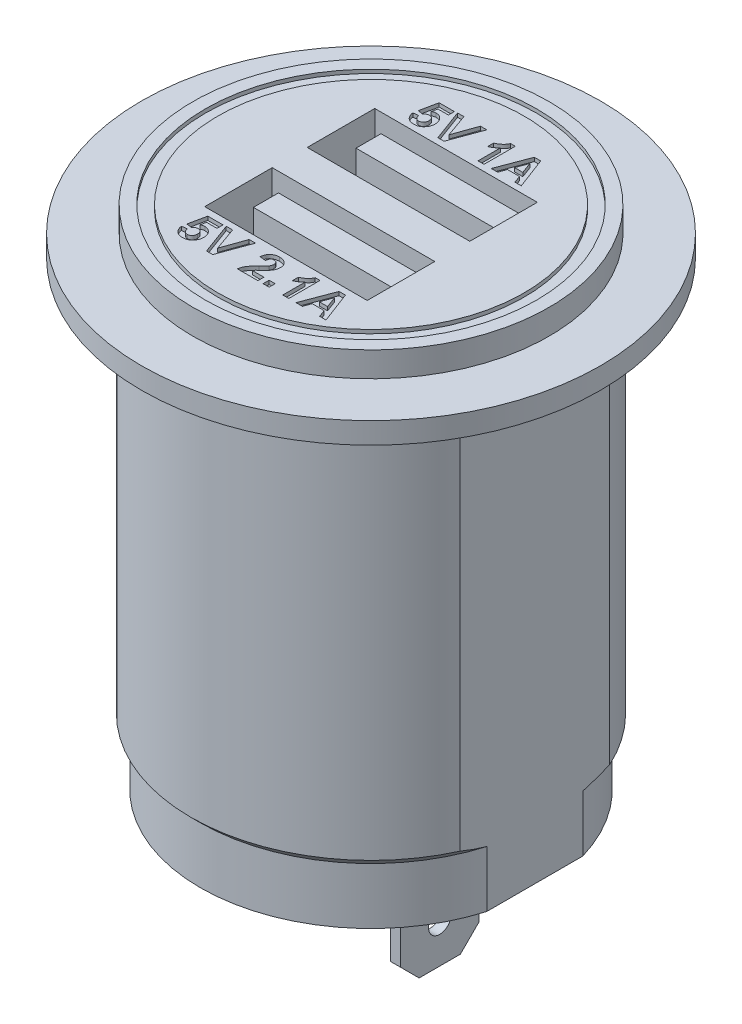
from build123d import *

# Parameters (mm, degrees)
SKETCH_2_W          = 2.6
SKETCH_2_H          = 11.958260744
CUT_EXTRUDE_1_DEPTH = 36.8
SKETCH_3_W          = 0.8
SKETCH_3_H          = 6.3
EXTRUDE_1_DEPTH     = 9.5
CHAMFER_1_SIZE      = 1.5
SKETCH_4_R          = 0.9
CUT_EXTRUDE_2_DEPTH = 24.85
SKETCH_5_W          = 13
SKETCH_5_H          = 5.4
CUT_EXTRUDE_3_DEPTH = 10
SKETCH_6_W          = 11
SKETCH_6_H          = 2
EXTRUDE_2_DEPTH     = 9
SKETCH_7_W          = 0.480769231
SKETCH_7_H          = 0.480769231
CUT_EXTRUDE_4_DEPTH = 0.3
SKETCH_8_R          = 13.25
SKETCH_8_R_2        = 12.25
CUT_EXTRUDE_5_DEPTH = 0.3


with BuildPart() as part:
    # Эскиз1 → Повернуть1 (revolve)
    with BuildSketch(Plane.XY):
        Polygon((0, 0), (-13.65, 0), (-13.65, 4.5), (-14.4, 5.25), (-14.4, 36.8), (-18.35, 36.8), (-18.35, 38.5), (-14.25, 38.5), (-14.25, 40.5), (0, 40.5), align=None)
    revolve(axis=Axis((0, 0, 0), (0, 1, 0)))

    # Эскиз2 → Вырез-Вытянуть1 (cut)
    with BuildSketch(Plane.XZ):
        with Locations((14.4, 0)):
            Rectangle(SKETCH_2_W, SKETCH_2_H)
        with Locations((-14.4, 0)):
            Rectangle(SKETCH_2_W, SKETCH_2_H)
    extrude(amount=-CUT_EXTRUDE_1_DEPTH, mode=Mode.SUBTRACT)

    # Эскиз3 → Бобышка-Вытянуть1 (add)
    with BuildSketch(Plane.XZ):
        with Locations((5.1, 0)):
            Rectangle(SKETCH_3_W, SKETCH_3_H)
        with Locations((-5.1, 0)):
            Rectangle(SKETCH_3_W, SKETCH_3_H)
    extrude(amount=EXTRUDE_1_DEPTH)

    # Фаска1
    chamfer_1_edges = [part.edges().sort_by_distance(p)[0] for p in [
        (5.1, -9.5, -3.15),
        (5.1, -9.5, 3.15),
        (-5.1, -9.5, -3.15),
        (-5.1, -9.5, 3.15),
    ]]
    chamfer(chamfer_1_edges, length=CHAMFER_1_SIZE)

    # Эскиз4 → Вырез-Вытянуть2 (cut, through all)
    with BuildSketch(Plane.ZY.offset(5.5)):
        with Locations((0, -6.4)):
            Circle(SKETCH_4_R)
    extrude(amount=-CUT_EXTRUDE_2_DEPTH, mode=Mode.SUBTRACT)

    # Эскиз5 → Вырез-Вытянуть3 (cut)
    with BuildSketch(Plane(origin=(0, 40.5, 0), x_dir=(1, 0, 0), z_dir=(0, 1, 0))):
        with Locations((0, 4.1)):
            Rectangle(SKETCH_5_W, SKETCH_5_H)
        with Locations((0, -4.1)):
            Rectangle(SKETCH_5_W, SKETCH_5_H)
    extrude(amount=-CUT_EXTRUDE_3_DEPTH, mode=Mode.SUBTRACT)

    # Эскиз6 → Бобышка-Вытянуть2 (add)
    with BuildSketch(Plane(origin=(0, 30.5, 0), x_dir=(1, 0, 0), z_dir=(0, 1, 0))):
        with Locations((0, 5.3)):
            Rectangle(SKETCH_6_W, SKETCH_6_H)
        with Locations((0, -2.9)):
            Rectangle(SKETCH_6_W, SKETCH_6_H)
    extrude(amount=EXTRUDE_2_DEPTH)

    # Эскиз7 → Вырез-Вытянуть4 (cut)
    with BuildSketch(Plane(origin=(0, 40.5, 0), x_dir=(1, 0, 0), z_dir=(0, 1, 0))):
        with BuildLine():
            Line((-6.071794872, -9.084855769), (-5.655128205, -9.030769231))
            add(Edge.make_bspline(
                [(-5.655128205, -9.030769231), (-5.65051875, -9.059026222), (-5.641642486, -9.113439714), (-5.614087877, -9.18940513), (-5.575714302, -9.256327628), (-5.526397261, -9.312679014), (-5.470268278, -9.358509144), (-5.408259878, -9.391182056), (-5.342250284, -9.411752917), (-5.296533961, -9.414168478), (-5.273517628, -9.415384615)],
                knots=[0, 0, 0, 0, 8.5742e-05, 0.000165111, 0.000240957, 0.000315865, 0.000388525, 0.000457076, 0.000525047, 0.000593964, 0.000593964, 0.000593964, 0.000593964], degree=3))
            add(Edge.make_bspline(
                [(-5.273517628, -9.415384615), (-5.260146267, -9.415149695), (-5.233971622, -9.414689835), (-5.195399511, -9.409469834), (-5.158552543, -9.400989158), (-5.123082097, -9.389479305), (-5.08935762, -9.374341406), (-5.057349128, -9.355816579), (-5.026937002, -9.333878798), (-4.997967309, -9.309072892), (-4.97119908, -9.280751154), (-4.948827523, -9.248150737), (-4.92900915, -9.212937652), (-4.912864338, -9.174155273), (-4.901226177, -9.131667688), (-4.891967182, -9.086202257), (-4.887247394, -9.037210068), (-4.886357083, -9.00356705), (-4.885897436, -8.986197917)],
                knots=[0, 0, 0, 0, 4.0092e-05, 7.8481e-05, 0.000116506, 0.000153406, 0.000190169, 0.000227192, 0.000264159, 0.000302509, 0.000341488, 0.000380669, 0.000420799, 0.000462558, 0.000506309, 0.000552765, 0.0006016, 0.000653722, 0.000653722, 0.000653722, 0.000653722], degree=3))
            add(Edge.make_bspline(
                [(-4.885897436, -8.986197917), (-4.886157335, -8.969825462), (-4.886659633, -8.938182995), (-4.891319785, -8.892338403), (-4.898473093, -8.849496208), (-4.909852877, -8.809969649), (-4.922849485, -8.773023923), (-4.94037219, -8.739968513), (-4.959599064, -8.709367422), (-4.983033703, -8.682871734), (-5.008567883, -8.659461096), (-5.035761697, -8.638602602), (-5.064920412, -8.621198196), (-5.095753688, -8.606260119), (-5.128796018, -8.595379296), (-5.163779387, -8.588140334), (-5.200233405, -8.582706053), (-5.22525255, -8.582271837), (-5.237960737, -8.582051282)],
                knots=[0, 0, 0, 0, 4.9102e-05, 9.4897e-05, 0.000138123, 0.000179191, 0.00021817, 0.000255351, 0.000291189, 0.000326335, 0.000361067, 0.000395022, 0.000428947, 0.000462773, 0.000497614, 0.000532976, 0.000569876, 0.000607967, 0.000607967, 0.000607967, 0.000607967], degree=3))
            add(Edge.make_bspline(
                [(-5.237960737, -8.582051282), (-5.254027815, -8.58262731), (-5.286081887, -8.583776496), (-5.333399457, -8.593118254), (-5.379455586, -8.6083267), (-5.424202404, -8.629497916), (-5.467521526, -8.656801079), (-5.509225401, -8.690326736), (-5.550029899, -8.729498078), (-5.575094389, -8.75909502), (-5.588020833, -8.774358974)],
                knots=[0, 0, 0, 0, 4.8171e-05, 9.6101e-05, 0.000144087, 0.000193372, 0.000244227, 0.000297334, 0.000353649, 0.000413622, 0.000413622, 0.000413622, 0.000413622], degree=3))
            Line((-5.588020833, -8.774358974), (-6.007692308, -8.715264423))
            Line((-6.007692308, -8.715264423), (-5.719230769, -7.332051282))
            Line((-5.719230769, -7.332051282), (-4.501282051, -7.332051282))
            Line((-4.501282051, -7.332051282), (-4.501282051, -7.812820513))
            Line((-4.501282051, -7.812820513), (-5.333613782, -7.812820513))
            Line((-5.333613782, -7.812820513), (-5.431770833, -8.259034455))
            add(Edge.make_bspline(
                [(-5.431770833, -8.259034455), (-5.406757602, -8.244602606), (-5.358046667, -8.216497927), (-5.280279335, -8.187566738), (-5.202112513, -8.168998235), (-5.149419679, -8.166582922), (-5.123277244, -8.165384615)],
                knots=[0, 0, 0, 0, 8.6492e-05, 0.000168436, 0.000248014, 0.00032637, 0.00032637, 0.00032637, 0.00032637], degree=3))
            add(Edge.make_bspline(
                [(-5.123277244, -8.165384615), (-5.098701132, -8.166045968), (-5.050153791, -8.167352395), (-4.978955064, -8.178071214), (-4.910661949, -8.195736928), (-4.845043836, -8.220320618), (-4.782570071, -8.252543421), (-4.722702089, -8.291489581), (-4.666304201, -8.33783492), (-4.612770435, -8.390241405), (-4.563951397, -8.448222876), (-4.521792274, -8.511448733), (-4.485378999, -8.578344249), (-4.455734276, -8.649648534), (-4.43341095, -8.725460788), (-4.416692937, -8.805128206), (-4.407327625, -8.889153856), (-4.405871334, -8.946445703), (-4.405128205, -8.97568109)],
                knots=[0, 0, 0, 0, 7.3701e-05, 0.000145588, 0.000215432, 0.000285007, 0.000355335, 0.000425899, 0.000498873, 0.00057395, 0.000650382, 0.000725804, 0.000801544, 0.000878552, 0.00095698, 0.001038304, 0.001122478, 0.001210188, 0.001210188, 0.001210188, 0.001210188], degree=3))
            add(Edge.make_bspline(
                [(-4.405128205, -8.97568109), (-4.405798933, -9.000236398), (-4.407130192, -9.048973779), (-4.414917043, -9.121095104), (-4.429453598, -9.191092415), (-4.447971061, -9.259360034), (-4.473562437, -9.325325991), (-4.503931524, -9.389420337), (-4.540234787, -9.451527978), (-4.568243305, -9.490713991), (-4.582411859, -9.510536859)],
                knots=[0, 0, 0, 0, 7.3679e-05, 0.000146238, 0.000217248, 0.000287966, 0.000358187, 0.000429196, 0.000500573, 0.000573643, 0.000573643, 0.000573643, 0.000573643], degree=3))
            add(Edge.make_bspline(
                [(-4.582411859, -9.510536859), (-4.603066772, -9.536061879), (-4.643718042, -9.586298089), (-4.713307615, -9.652346218), (-4.7889948, -9.707815105), (-4.870574601, -9.75336909), (-4.957960108, -9.789116493), (-5.051545596, -9.813969732), (-5.150644882, -9.829346086), (-5.218706018, -9.831136415), (-5.253485577, -9.832051282)],
                knots=[0, 0, 0, 0, 9.8429e-05, 0.000193719, 0.000286874, 0.000379245, 0.00047336, 0.000569333, 0.000669128, 0.000773415, 0.000773415, 0.000773415, 0.000773415], degree=3))
            add(Edge.make_bspline(
                [(-5.253485577, -9.832051282), (-5.281558918, -9.831544204), (-5.336373649, -9.830554105), (-5.416648595, -9.820762771), (-5.492722758, -9.804855481), (-5.565076081, -9.782780924), (-5.633278959, -9.754111375), (-5.697861313, -9.719498174), (-5.758285061, -9.678174124), (-5.814271958, -9.630451413), (-5.865683396, -9.577703979), (-5.911540136, -9.519988728), (-5.952340623, -9.458270932), (-5.987306455, -9.391926961), (-6.017105607, -9.321422091), (-6.040832947, -9.246394983), (-6.060368841, -9.167345985), (-6.067944037, -9.112656866), (-6.071794872, -9.084855769)],
                knots=[0, 0, 0, 0, 8.4188e-05, 0.000164382, 0.000242173, 0.000317101, 0.00039095, 0.000463773, 0.00053656, 0.000610109, 0.000684128, 0.000757178, 0.000830934, 0.00090576, 0.000981843, 0.001060239, 0.001141622, 0.001225769, 0.001225769, 0.001225769, 0.001225769], degree=3))
        make_face()
        Polygon((-3.35244391, -9.8), (-4.276923077, -7.3), (-3.769110577, -7.3), (-3.107051282, -9.158974359), (-2.447495994, -7.3), (-1.937179487, -7.3), (-2.858153045, -9.8), align=None)
        with BuildLine():
            Line((0.755128205, -9.319230769), (0.755128205, -9.8))
            Line((0.755128205, -9.8), (-0.879487179, -9.8))
            add(Edge.make_bspline(
                [(-0.879487179, -9.8), (-0.873952751, -9.758911294), (-0.862886996, -9.67675692), (-0.828675638, -9.556750059), (-0.783015195, -9.439643865), (-0.733459457, -9.344347849), (-0.684170786, -9.267637836), (-0.639451172, -9.204781058), (-0.586102314, -9.137904144), (-0.524898363, -9.066467212), (-0.456177556, -8.990246952), (-0.379427192, -8.909526734), (-0.294281159, -8.824692989), (-0.234379408, -8.767086702), (-0.203405449, -8.737299679)],
                knots=[0, 0, 0, 0, 0.000124241, 0.000248413, 0.000373217, 0.000500896, 0.000569803, 0.00064665, 0.000732215, 0.000826351, 0.00092883, 0.001040059, 0.00116046, 0.001289377, 0.001289377, 0.001289377, 0.001289377], degree=3))
            add(Edge.make_bspline(
                [(-0.203405449, -8.737299679), (-0.178687875, -8.713440453), (-0.131632893, -8.668019514), (-0.064626509, -8.60297857), (-0.005720992, -8.543187455), (0.046315289, -8.490195613), (0.090280224, -8.442653738), (0.12675213, -8.401308468), (0.15619292, -8.365991431), (0.172138077, -8.343586281), (0.179206731, -8.333653846)],
                knots=[0, 0, 0, 0, 0.000103064, 0.000196204, 0.000280131, 0.000354858, 0.000419001, 0.000474358, 0.00052027, 0.000556832, 0.000556832, 0.000556832, 0.000556832], degree=3))
            add(Edge.make_bspline(
                [(0.179206731, -8.333653846), (0.193681608, -8.309609529), (0.221601969, -8.263230827), (0.252218961, -8.190299479), (0.270596421, -8.117383196), (0.273118305, -8.068660953), (0.274358974, -8.044691506)],
                knots=[0, 0, 0, 0, 8.4106e-05, 0.000162231, 0.000236446, 0.000308313, 0.000308313, 0.000308313, 0.000308313], degree=3))
            add(Edge.make_bspline(
                [(0.274358974, -8.044691506), (0.273458558, -8.019748074), (0.27175504, -7.972557046), (0.257470747, -7.905961778), (0.232139873, -7.848713712), (0.19726392, -7.800637123), (0.153163208, -7.762969299), (0.101608193, -7.735136433), (0.041844192, -7.719748486), (-0.000161473, -7.717724491), (-0.022115385, -7.716666667)],
                knots=[0, 0, 0, 0, 7.4787e-05, 0.000141492, 0.000202917, 0.000261313, 0.000318132, 0.000375488, 0.00043562, 0.000501456, 0.000501456, 0.000501456, 0.000501456], degree=3))
            add(Edge.make_bspline(
                [(-0.022115385, -7.716666667), (-0.043920977, -7.717654596), (-0.086044675, -7.719563061), (-0.145911589, -7.736235151), (-0.19828409, -7.765096294), (-0.235607519, -7.79798635), (-0.260821266, -7.829969541), (-0.278001033, -7.857840785), (-0.292808651, -7.889511066), (-0.305929437, -7.924623828), (-0.316293374, -7.963581325), (-0.324639845, -8.006086858), (-0.331365894, -8.052369166), (-0.333504896, -8.084566443), (-0.334615385, -8.101282051)],
                knots=[0, 0, 0, 0, 6.5337e-05, 0.000126217, 0.000184491, 0.000243381, 0.000274041, 0.000306423, 0.000341368, 0.000378764, 0.000418734, 0.000462145, 0.000508677, 0.000558917, 0.000558917, 0.000558917, 0.000558917], degree=3))
            Line((-0.334615385, -8.101282051), (-0.815384615, -8.054206731))
            add(Edge.make_bspline(
                [(-0.815384615, -8.054206731), (-0.811519305, -8.021748748), (-0.804025086, -7.958817905), (-0.785323138, -7.868427517), (-0.761637813, -7.785038303), (-0.731839952, -7.70880502), (-0.697161138, -7.639242897), (-0.655832462, -7.577395758), (-0.609297991, -7.522578511), (-0.55751751, -7.474820331), (-0.500820204, -7.433969287), (-0.441326555, -7.397503461), (-0.37787389, -7.367589892), (-0.311160825, -7.342936617), (-0.24121751, -7.323233917), (-0.167720447, -7.310206758), (-0.091123232, -7.301043405), (-0.038837654, -7.300353044), (-0.012099359, -7.3)],
                knots=[0, 0, 0, 0, 9.8024e-05, 0.000190053, 0.000276592, 0.00035778, 0.000435274, 0.000509306, 0.000580356, 0.000650529, 0.000720045, 0.000789699, 0.000859589, 0.000930103, 0.001002885, 0.001077241, 0.001153838, 0.001234005, 0.001234005, 0.001234005, 0.001234005], degree=3))
            add(Edge.make_bspline(
                [(-0.012099359, -7.3), (0.016968622, -7.300558671), (0.073582164, -7.301646754), (0.156227886, -7.310632151), (0.233867603, -7.326299493), (0.307180097, -7.347053105), (0.375412488, -7.374760693), (0.439133353, -7.408258016), (0.497339838, -7.448816364), (0.55089959, -7.494223917), (0.598777722, -7.544157504), (0.640714634, -7.597420115), (0.67584924, -7.653974645), (0.70533257, -7.713131754), (0.727223744, -7.775843368), (0.743174605, -7.841242356), (0.753750669, -7.909633819), (0.754663948, -7.956343636), (0.755128205, -7.980088141)],
                knots=[0, 0, 0, 0, 8.7191e-05, 0.000169816, 0.000248977, 0.000324578, 0.000398046, 0.000469513, 0.000540082, 0.000610426, 0.000679848, 0.000747271, 0.000813414, 0.000879262, 0.000945155, 0.001012202, 0.001081044, 0.001152221, 0.001152221, 0.001152221, 0.001152221], degree=3))
            add(Edge.make_bspline(
                [(0.755128205, -7.980088141), (0.754516553, -8.007339288), (0.753303128, -8.061401383), (0.741685485, -8.141321309), (0.723935988, -8.219398293), (0.69770363, -8.295823146), (0.664452079, -8.372429123), (0.621590033, -8.449388173), (0.571823955, -8.529021246), (0.532859078, -8.580507502), (0.512740385, -8.607091346)],
                knots=[0, 0, 0, 0, 8.1706e-05, 0.000162092, 0.000241782, 0.0003216, 0.000404129, 0.000491979, 0.000585622, 0.000685588, 0.000685588, 0.000685588, 0.000685588], degree=3))
            add(Edge.make_bspline(
                [(0.512740385, -8.607091346), (0.505136402, -8.616668585), (0.488850433, -8.637180811), (0.46114372, -8.668633137), (0.429034023, -8.702988993), (0.392974878, -8.740891439), (0.351775179, -8.780998248), (0.306917294, -8.824986654), (0.256427346, -8.870606505), (0.204131995, -8.918995794), (0.151609333, -8.966092408), (0.103333434, -9.01082375), (0.059482854, -9.050401381), (0.022099797, -9.087010167), (-0.011014599, -9.118151585), (-0.038666782, -9.14542253), (-0.061374189, -9.168162796), (-0.092663535, -9.2036091), (-0.132475676, -9.251550242), (-0.160485145, -9.297359359), (-0.173858173, -9.319230769)],
                knots=[0, 0, 0, 0, 3.6682e-05, 7.8564e-05, 0.000125695, 0.000177762, 0.000235484, 0.000298172, 0.000366222, 0.000439595, 0.000511922, 0.000577849, 0.000637039, 0.000689105, 0.000734799, 0.0007734, 0.000805627, 0.000831163, 0.000915241, 0.000992061, 0.000992061, 0.000992061, 0.000992061], degree=3))
            Line((-0.173858173, -9.319230769), (0.755128205, -9.319230769))
        make_face()
        with Locations((1.412179487, -9.559615385)):
            Rectangle(SKETCH_7_W, SKETCH_7_H)
        with BuildLine():
            Line((3.223076923, -9.8), (2.742307692, -9.8))
            Line((2.742307692, -9.8), (2.742307692, -8.020152244))
            add(Edge.make_bspline(
                [(2.742307692, -8.020152244), (2.720516648, -8.042274218), (2.677230179, -8.08621806), (2.608094868, -8.147513859), (2.536321875, -8.204535114), (2.46120094, -8.256740226), (2.383714086, -8.304873027), (2.30306944, -8.34855373), (2.219851545, -8.388386718), (2.162202905, -8.410647172), (2.133333333, -8.421794872)],
                knots=[0, 0, 0, 0, 9.3134e-05, 0.000185005, 0.000276984, 0.000367982, 0.000459289, 0.000550496, 0.000643016, 0.000735826, 0.000735826, 0.000735826, 0.000735826], degree=3))
            Line((2.133333333, -8.421794872), (2.133333333, -7.941025641))
            add(Edge.make_bspline(
                [(2.133333333, -7.941025641), (2.165351142, -7.929020337), (2.232361924, -7.903894169), (2.331247303, -7.850449537), (2.434461306, -7.78427969), (2.52116696, -7.719382394), (2.590007686, -7.661683511), (2.638122119, -7.615302663), (2.682702908, -7.567806269), (2.722074349, -7.517661319), (2.757269962, -7.465881633), (2.788454809, -7.412551804), (2.815904643, -7.357503364), (2.83027444, -7.319168851), (2.837459936, -7.3)],
                knots=[0, 0, 0, 0, 0.000102482, 0.000214487, 0.000336323, 0.000470137, 0.00053907, 0.000605659, 0.000670511, 0.000734333, 0.0007967, 0.000858199, 0.000919567, 0.000980945, 0.000980945, 0.000980945, 0.000980945], degree=3))
            Line((2.837459936, -7.3), (3.223076923, -7.3))
            Line((3.223076923, -7.3), (3.223076923, -9.8))
        make_face()
        Polygon((6.203846154, -9.8), (5.694030449, -9.8), (5.483193109, -9.223076923), (4.523657853, -9.223076923), (4.312820513, -9.8), (3.8, -9.8), (4.745012019, -7.3), (5.254326923, -7.3), align=None)
        Polygon((5.330448718, -8.806410256), (5.001923077, -7.908974359), (4.674399038, -8.806410256), align=None, mode=Mode.SUBTRACT)
        with BuildLine():
            Line((-4.671794872, 8.015144231), (-4.255128205, 8.069230769))
            add(Edge.make_bspline(
                [(-4.255128205, 8.069230769), (-4.25051875, 8.040973778), (-4.241642486, 7.986560286), (-4.214087877, 7.91059487), (-4.175714302, 7.843672372), (-4.126397261, 7.787320986), (-4.070268278, 7.741490856), (-4.008259878, 7.708817944), (-3.942250284, 7.688247083), (-3.896533961, 7.685831522), (-3.873517628, 7.684615385)],
                knots=[0, 0, 0, 0, 8.5742e-05, 0.000165111, 0.000240957, 0.000315865, 0.000388525, 0.000457076, 0.000525047, 0.000593964, 0.000593964, 0.000593964, 0.000593964], degree=3))
            add(Edge.make_bspline(
                [(-3.873517628, 7.684615385), (-3.860146267, 7.684850305), (-3.833971622, 7.685310165), (-3.795399511, 7.690530166), (-3.758552543, 7.699010842), (-3.723082097, 7.710520695), (-3.68935762, 7.725658594), (-3.657349128, 7.744183421), (-3.626937002, 7.766121202), (-3.597967309, 7.790927108), (-3.57119908, 7.819248846), (-3.548827523, 7.851849263), (-3.52900915, 7.887062348), (-3.512864338, 7.925844727), (-3.501226177, 7.968332312), (-3.491967182, 8.013797743), (-3.487247394, 8.062789932), (-3.486357083, 8.09643295), (-3.485897436, 8.113802083)],
                knots=[0, 0, 0, 0, 4.0092e-05, 7.8481e-05, 0.000116506, 0.000153406, 0.000190169, 0.000227192, 0.000264159, 0.000302509, 0.000341488, 0.000380669, 0.000420799, 0.000462558, 0.000506309, 0.000552765, 0.0006016, 0.000653722, 0.000653722, 0.000653722, 0.000653722], degree=3))
            add(Edge.make_bspline(
                [(-3.485897436, 8.113802083), (-3.486157335, 8.130174538), (-3.486659633, 8.161817005), (-3.491319785, 8.207661597), (-3.498473093, 8.250503792), (-3.509852877, 8.290030351), (-3.522849485, 8.326976077), (-3.54037219, 8.360031487), (-3.559599064, 8.390632578), (-3.583033703, 8.417128266), (-3.608567883, 8.440538904), (-3.635761697, 8.461397398), (-3.664920412, 8.478801804), (-3.695753688, 8.493739881), (-3.728796018, 8.504620704), (-3.763779387, 8.511859666), (-3.800233405, 8.517293947), (-3.82525255, 8.517728163), (-3.837960737, 8.517948718)],
                knots=[0, 0, 0, 0, 4.9102e-05, 9.4897e-05, 0.000138123, 0.000179191, 0.00021817, 0.000255351, 0.000291189, 0.000326335, 0.000361067, 0.000395022, 0.000428947, 0.000462773, 0.000497614, 0.000532976, 0.000569876, 0.000607967, 0.000607967, 0.000607967, 0.000607967], degree=3))
            add(Edge.make_bspline(
                [(-3.837960737, 8.517948718), (-3.854027815, 8.51737269), (-3.886081887, 8.516223504), (-3.933399457, 8.506881746), (-3.979455586, 8.4916733), (-4.024202404, 8.470502084), (-4.067521526, 8.443198921), (-4.109225401, 8.409673264), (-4.150029899, 8.370501922), (-4.175094389, 8.34090498), (-4.188020833, 8.325641026)],
                knots=[0, 0, 0, 0, 4.8171e-05, 9.6101e-05, 0.000144087, 0.000193372, 0.000244227, 0.000297334, 0.000353649, 0.000413622, 0.000413622, 0.000413622, 0.000413622], degree=3))
            Line((-4.188020833, 8.325641026), (-4.607692308, 8.384735577))
            Line((-4.607692308, 8.384735577), (-4.319230769, 9.767948718))
            Line((-4.319230769, 9.767948718), (-3.101282051, 9.767948718))
            Line((-3.101282051, 9.767948718), (-3.101282051, 9.287179487))
            Line((-3.101282051, 9.287179487), (-3.933613782, 9.287179487))
            Line((-3.933613782, 9.287179487), (-4.031770833, 8.840965545))
            add(Edge.make_bspline(
                [(-4.031770833, 8.840965545), (-4.006757602, 8.855397394), (-3.958046667, 8.883502073), (-3.880279335, 8.912433262), (-3.802112513, 8.931001765), (-3.749419679, 8.933417078), (-3.723277244, 8.934615385)],
                knots=[0, 0, 0, 0, 8.6492e-05, 0.000168436, 0.000248014, 0.00032637, 0.00032637, 0.00032637, 0.00032637], degree=3))
            add(Edge.make_bspline(
                [(-3.723277244, 8.934615385), (-3.698701132, 8.933954032), (-3.650153791, 8.932647605), (-3.578955064, 8.921928786), (-3.510661949, 8.904263072), (-3.445043836, 8.879679382), (-3.382570071, 8.847456579), (-3.322702089, 8.808510419), (-3.266304201, 8.76216508), (-3.212770435, 8.709758595), (-3.163951397, 8.651777124), (-3.121792274, 8.588551267), (-3.085378999, 8.521655751), (-3.055734276, 8.450351466), (-3.03341095, 8.374539212), (-3.016692937, 8.294871794), (-3.007327625, 8.210846144), (-3.005871334, 8.153554297), (-3.005128205, 8.12431891)],
                knots=[0, 0, 0, 0, 7.3701e-05, 0.000145588, 0.000215432, 0.000285007, 0.000355335, 0.000425899, 0.000498873, 0.00057395, 0.000650382, 0.000725804, 0.000801544, 0.000878552, 0.00095698, 0.001038304, 0.001122478, 0.001210188, 0.001210188, 0.001210188, 0.001210188], degree=3))
            add(Edge.make_bspline(
                [(-3.005128205, 8.12431891), (-3.005798933, 8.099763602), (-3.007130192, 8.051026221), (-3.014917043, 7.978904896), (-3.029453598, 7.908907585), (-3.047971061, 7.840639966), (-3.073562437, 7.774674009), (-3.103931524, 7.710579663), (-3.140234787, 7.648472022), (-3.168243305, 7.609286009), (-3.182411859, 7.589463141)],
                knots=[0, 0, 0, 0, 7.3679e-05, 0.000146238, 0.000217248, 0.000287966, 0.000358187, 0.000429196, 0.000500573, 0.000573643, 0.000573643, 0.000573643, 0.000573643], degree=3))
            add(Edge.make_bspline(
                [(-3.182411859, 7.589463141), (-3.203066772, 7.563938121), (-3.243718042, 7.513701911), (-3.313307615, 7.447653782), (-3.3889948, 7.392184895), (-3.470574601, 7.34663091), (-3.557960108, 7.310883507), (-3.651545596, 7.286030268), (-3.750644882, 7.270653914), (-3.818706018, 7.268863585), (-3.853485577, 7.267948718)],
                knots=[0, 0, 0, 0, 9.8429e-05, 0.000193719, 0.000286874, 0.000379245, 0.00047336, 0.000569333, 0.000669128, 0.000773415, 0.000773415, 0.000773415, 0.000773415], degree=3))
            add(Edge.make_bspline(
                [(-3.853485577, 7.267948718), (-3.881558918, 7.268455796), (-3.936373649, 7.269445895), (-4.016648595, 7.279237229), (-4.092722758, 7.295144519), (-4.165076081, 7.317219076), (-4.233278959, 7.345888625), (-4.297861313, 7.380501826), (-4.358285061, 7.421825876), (-4.414271958, 7.469548587), (-4.465683396, 7.522296021), (-4.511540136, 7.580011272), (-4.552340623, 7.641729068), (-4.587306455, 7.708073039), (-4.617105607, 7.778577909), (-4.640832947, 7.853605017), (-4.660368841, 7.932654015), (-4.667944037, 7.987343134), (-4.671794872, 8.015144231)],
                knots=[0, 0, 0, 0, 8.4188e-05, 0.000164382, 0.000242173, 0.000317101, 0.00039095, 0.000463773, 0.00053656, 0.000610109, 0.000684128, 0.000757178, 0.000830934, 0.00090576, 0.000981843, 0.001060239, 0.001141622, 0.001225769, 0.001225769, 0.001225769, 0.001225769], degree=3))
        make_face()
        Polygon((-1.95244391, 7.3), (-2.876923077, 9.8), (-2.369110577, 9.8), (-1.707051282, 7.941025641), (-1.047495994, 9.8), (-0.537179487, 9.8), (-1.458153045, 7.3), align=None)
        with BuildLine():
            Line((1.738461538, 7.3), (1.257692308, 7.3))
            Line((1.257692308, 7.3), (1.257692308, 9.079847756))
            add(Edge.make_bspline(
                [(1.257692308, 9.079847756), (1.235901263, 9.057725782), (1.192614794, 9.01378194), (1.123479483, 8.952486141), (1.05170649, 8.895464886), (0.976585555, 8.843259774), (0.899098701, 8.795126973), (0.818454056, 8.75144627), (0.73523616, 8.711613282), (0.67758752, 8.689352828), (0.648717949, 8.678205128)],
                knots=[0, 0, 0, 0, 9.3134e-05, 0.000185005, 0.000276984, 0.000367982, 0.000459289, 0.000550496, 0.000643016, 0.000735826, 0.000735826, 0.000735826, 0.000735826], degree=3))
            Line((0.648717949, 8.678205128), (0.648717949, 9.158974359))
            add(Edge.make_bspline(
                [(0.648717949, 9.158974359), (0.680735757, 9.170979663), (0.747746539, 9.196105831), (0.846631919, 9.249550463), (0.949845921, 9.31572031), (1.036551576, 9.380617606), (1.105392301, 9.438316489), (1.153506734, 9.484697337), (1.198087523, 9.532193731), (1.237458965, 9.582338681), (1.272654577, 9.634118367), (1.303839425, 9.687448196), (1.331289259, 9.742496636), (1.345659055, 9.780831149), (1.352844551, 9.8)],
                knots=[0, 0, 0, 0, 0.000102482, 0.000214487, 0.000336323, 0.000470137, 0.00053907, 0.000605659, 0.000670511, 0.000734333, 0.0007967, 0.000858199, 0.000919567, 0.000980945, 0.000980945, 0.000980945, 0.000980945], degree=3))
            Line((1.352844551, 9.8), (1.738461538, 9.8))
            Line((1.738461538, 9.8), (1.738461538, 7.3))
        make_face()
        Polygon((4.719230769, 7.3), (4.209415064, 7.3), (3.998577724, 7.876923077), (3.039042468, 7.876923077), (2.828205128, 7.3), (2.315384615, 7.3), (3.260396635, 9.8), (3.769711538, 9.8), align=None)
        Polygon((3.845833333, 8.293589744), (3.517307692, 9.191025641), (3.189783654, 8.293589744), align=None, mode=Mode.SUBTRACT)
    extrude(amount=-CUT_EXTRUDE_4_DEPTH, mode=Mode.SUBTRACT)

    # Эскиз8 → Вырез-Вытянуть5 (cut)
    with BuildSketch(Plane(origin=(0, 40.5, 0), x_dir=(1, 0, 0), z_dir=(0, 1, 0))):
        Circle(SKETCH_8_R)
        Circle(SKETCH_8_R_2, mode=Mode.SUBTRACT)
    extrude(amount=-CUT_EXTRUDE_5_DEPTH, mode=Mode.SUBTRACT)


solid = part.part
